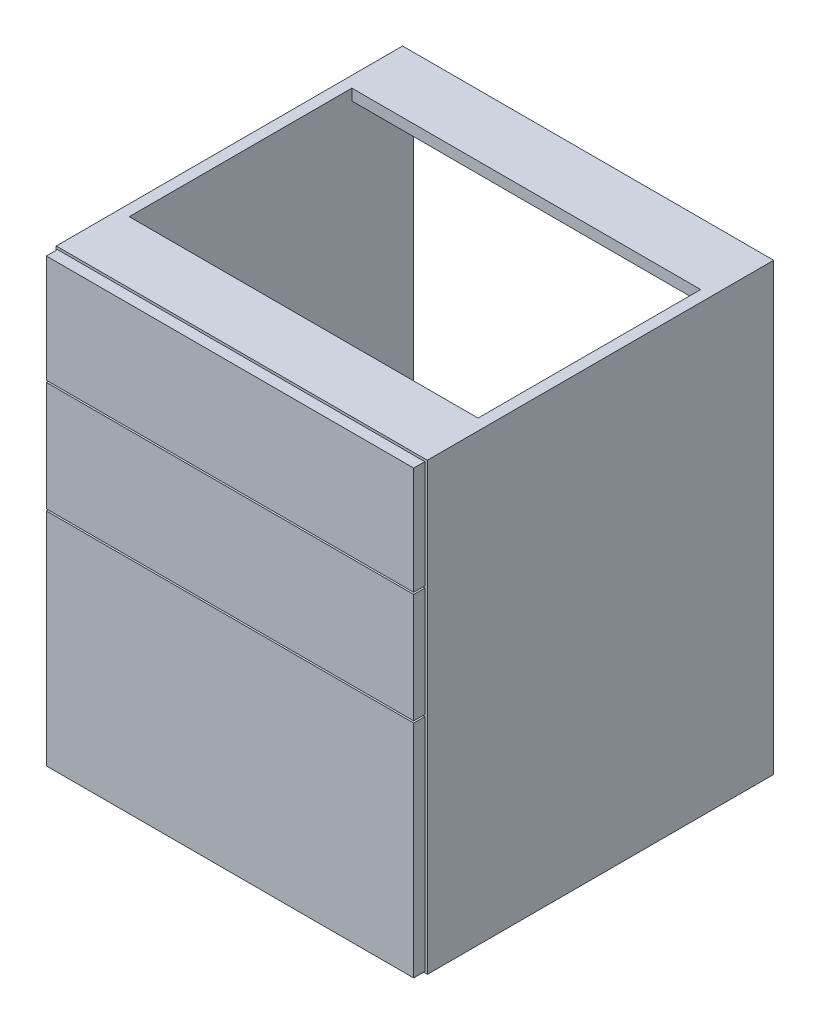
from build123d import *

# Parameters (mm, degrees)
SKETCH1_W           = 600
SKETCH1_H           = 720
BOSS_EXTRUDE1_DEPTH = 560
SKETCH2_W           = 564
SKETCH2_H           = 684
CUT_EXTRUDE1_DEPTH  = 561
SKETCH3_W           = 564
SKETCH3_H           = 360
CUT_EXTRUDE2_DEPTH  = 702
SKETCH4_W           = 594
SKETCH4_H           = 714
BOSS_EXTRUDE2_DEPTH = 18
SKETCH5_W           = 594
SKETCH5_H           = 3
CUT_EXTRUDE3_DEPTH  = 18
SKETCH6_W           = 594
SKETCH6_H           = 3
CUT_EXTRUDE4_DEPTH  = 18


with BuildPart() as part:
    # Sketch1 → Boss-Extrude1 (new body)
    with BuildSketch(Plane.XY):
        with Locations((300, 360)):
            Rectangle(SKETCH1_W, SKETCH1_H)
    extrude(amount=-BOSS_EXTRUDE1_DEPTH)

    # Sketch2 → Cut-Extrude1 (cut, through all)
    with BuildSketch(Plane.XY):
        with Locations((300, 360)):
            Rectangle(SKETCH2_W, SKETCH2_H)
    extrude(amount=-CUT_EXTRUDE1_DEPTH, mode=Mode.SUBTRACT)

    # Sketch3 → Cut-Extrude2 (cut)
    with BuildSketch(Plane(origin=(0, 720, 0), x_dir=(1, 0, 0), z_dir=(0, 1, 0))):
        with Locations((300, 280)):
            Rectangle(SKETCH3_W, SKETCH3_H)
    extrude(amount=-CUT_EXTRUDE2_DEPTH, mode=Mode.SUBTRACT)


with BuildPart() as body_2:
    # Sketch4 → Boss-Extrude2 (new body)
    with BuildSketch(Plane.XY.offset(1)):
        with Locations((300, 360)):
            Rectangle(SKETCH4_W, SKETCH4_H)
    extrude(amount=BOSS_EXTRUDE2_DEPTH)

    # Sketch5 → Cut-Extrude3 (cut)
    with BuildSketch(Plane.XY.offset(19)):
        with Locations((300, 361.5)):
            Rectangle(SKETCH5_W, SKETCH5_H)
    extrude(amount=-CUT_EXTRUDE3_DEPTH, mode=Mode.SUBTRACT)

    # Sketch6 → Cut-Extrude4 (cut)
    with BuildSketch(Plane.XY.offset(19)):
        with Locations((300, 541.5)):
            Rectangle(SKETCH6_W, SKETCH6_H)
    extrude(amount=-CUT_EXTRUDE4_DEPTH, mode=Mode.SUBTRACT)


solid = Compound([part.part, body_2.part])
